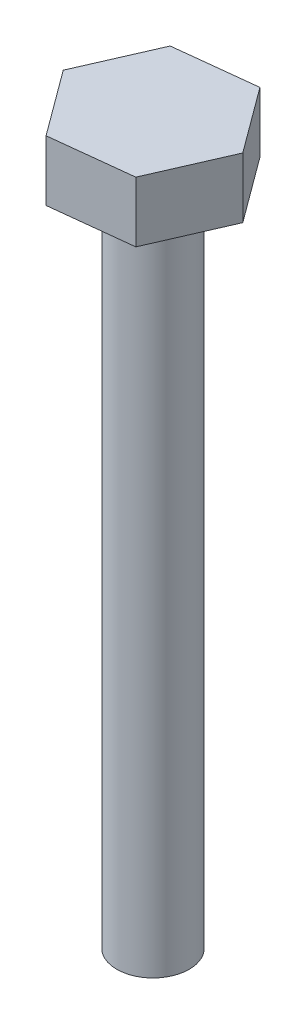
from build123d import *

# Parameters (mm, degrees)
BOSS_EXTRUDE1_DEPTH = 10
SKETCH2_R           = 6
BOSS_EXTRUDE2_DEPTH = 110


with BuildPart() as part:
    # Sketch1 → Boss-Extrude1 (new body)
    with BuildSketch(Plane(origin=(0, 0, 0), x_dir=(1, 0, 0), z_dir=(0, 1, 0))):
        Polygon((7.979415777, -10.824700142), (13.3641732, 1.498026699), (5.384757423, 12.322726841), (-7.979415777, 10.824700142), (-13.3641732, -1.498026699), (-5.384757423, -12.322726841), align=None)
    extrude(amount=BOSS_EXTRUDE1_DEPTH)

    # Sketch2 → Boss-Extrude2 (add)
    with BuildSketch(Plane.XZ):
        Circle(SKETCH2_R)
    extrude(amount=BOSS_EXTRUDE2_DEPTH)


solid = part.part
